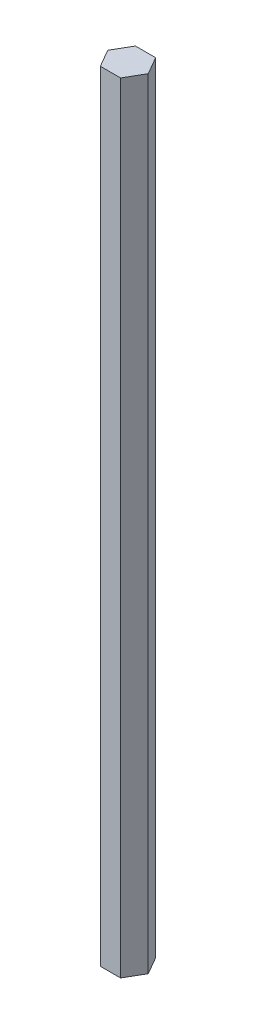
from build123d import *

# Parameters (mm, degrees)
BOSS_EXTRUDE1_DEPTH = 55.5625


with BuildPart() as part:
    # Sketch1 → Boss-Extrude1 (new, symmetric)
    with BuildSketch(Plane(origin=(0, 0, 0), x_dir=(1, 0, 0), z_dir=(0, 1, 0))):
        Polygon((2.886751346, 0), (1.443375673, 2.5), (-1.443375673, 2.5), (-2.886751346, 0), (-1.443375673, -2.5), (1.443375673, -2.5), align=None)
    extrude(amount=BOSS_EXTRUDE1_DEPTH, both=True)


solid = part.part
